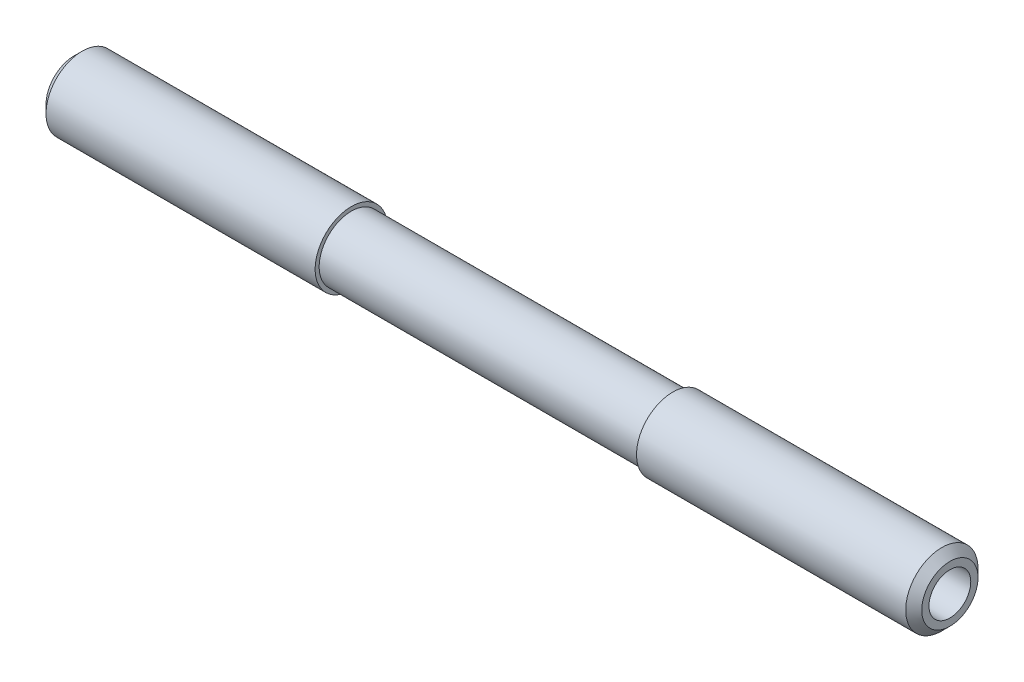
from build123d import *

# Parameters (mm, degrees)
ESQUISSE1_R             = 4.5
ESQUISSE1_R_2           = 2.6
EXTRUSION1_DEPTH        = 54.5
ESQUISSE2_OUTSIDE_W     = 32.948
ESQUISSE2_OUTSIDE_H     = 32.948
ESQUISSE2_OUTSIDE_R     = 4
ENL_V_MAT_EXTRU_1_DEPTH = 20
CHANFREIN1_SIZE         = 1


with BuildPart() as part:
    # Esquisse1 → Extrusion1 (new body, symmetric)
    with BuildSketch(Plane(origin=(0, 0, 0), x_dir=(0, 0, -1), z_dir=(1, 0, 0))):
        Circle(ESQUISSE1_R)
        Circle(ESQUISSE1_R_2, mode=Mode.SUBTRACT)
    extrude(amount=EXTRUSION1_DEPTH, both=True)

    # Esquisse2 outside → Enlèv. mat.-Extru.1 (cut, symmetric)
    with BuildSketch(Plane(origin=(0, 0, 0), x_dir=(0, 0, -1), z_dir=(1, 0, 0))):
        Rectangle(ESQUISSE2_OUTSIDE_W, ESQUISSE2_OUTSIDE_H)
        Circle(ESQUISSE2_OUTSIDE_R, mode=Mode.SUBTRACT)
    extrude(amount=ENL_V_MAT_EXTRU_1_DEPTH, both=True, mode=Mode.SUBTRACT)

    # Chanfrein1
    chanfrein1_edges = [part.edges().sort_by_distance(p)[0] for p in [
        (-54.5, 0, 4.5),
        (54.5, 0, 4.5),
    ]]
    chamfer(chanfrein1_edges, length=CHANFREIN1_SIZE)


solid = part.part
